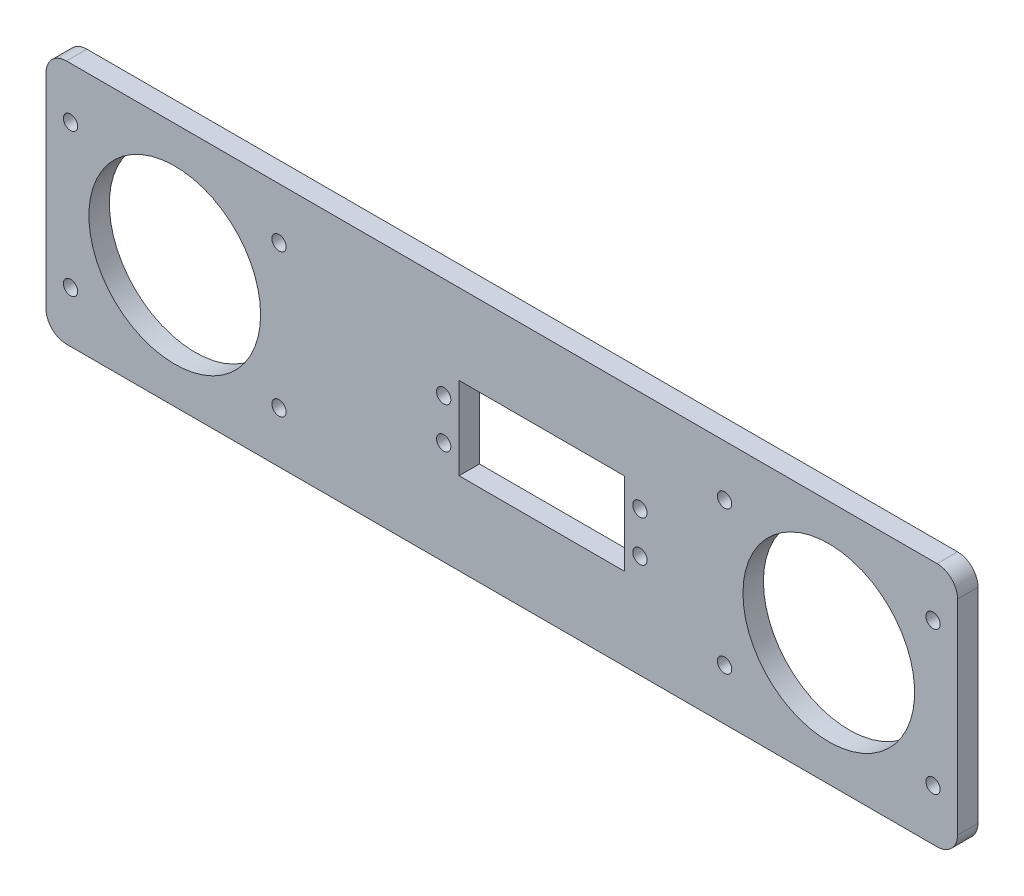
from build123d import *

# Parameters (mm, degrees)
SKETCH_1_R      = 21
SKETCH_1_R_2    = 1.75
SKETCH_1_W      = 40.5
SKETCH_1_H      = 20.2
EXTRUDE_1_DEPTH = 5


with BuildPart() as part:
    # 草图1 → 凸台-拉伸1 (new body)
    with BuildSketch(Plane.XY):
        with BuildLine():
            Line((106.5, -30), (-106.5, -30))
            ThreePointArc((-106.5, -30), (-110.035533906, -28.535533906), (-111.5, -25))
            Line((-111.5, -25), (-111.5, 25))
            ThreePointArc((-111.5, 25), (-110.035533906, 28.535533906), (-106.5, 30))
            Line((-106.5, 30), (106.5, 30))
            ThreePointArc((106.5, 30), (110.035533906, 28.535533906), (111.5, 25))
            Line((111.5, 25), (111.5, -25))
            ThreePointArc((111.5, -25), (110.035533906, -28.535533906), (106.5, -30))
        make_face()
        with Locations((-80, 0)):
            Circle(SKETCH_1_R, mode=Mode.SUBTRACT)
        with Locations((80, 0)):
            Circle(SKETCH_1_R, mode=Mode.SUBTRACT)
        with Locations((33.788860906, -4.762314657)):
            Circle(SKETCH_1_R_2, mode=Mode.SUBTRACT)
        with Locations((33.788860906, 5.237685343)):
            Circle(SKETCH_1_R_2, mode=Mode.SUBTRACT)
        with Locations((-14.211139094, -4.762314657)):
            Circle(SKETCH_1_R_2, mode=Mode.SUBTRACT)
        with Locations((-14.211139094, 5.237685343)):
            Circle(SKETCH_1_R_2, mode=Mode.SUBTRACT)
        with Locations((-54.5, -17.5)):
            Circle(SKETCH_1_R_2, mode=Mode.SUBTRACT)
        with Locations((-105.5, -17.5)):
            Circle(SKETCH_1_R_2, mode=Mode.SUBTRACT)
        with Locations((-105.5, 17.5)):
            Circle(SKETCH_1_R_2, mode=Mode.SUBTRACT)
        with Locations((-54.5, 17.5)):
            Circle(SKETCH_1_R_2, mode=Mode.SUBTRACT)
        with Locations((54.5, -17.5)):
            Circle(SKETCH_1_R_2, mode=Mode.SUBTRACT)
        with Locations((54.5, 17.5)):
            Circle(SKETCH_1_R_2, mode=Mode.SUBTRACT)
        with Locations((105.5, -17.5)):
            Circle(SKETCH_1_R_2, mode=Mode.SUBTRACT)
        with Locations((105.5, 17.5)):
            Circle(SKETCH_1_R_2, mode=Mode.SUBTRACT)
        with Locations((9.788860906, 0.237685343)):
            Rectangle(SKETCH_1_W, SKETCH_1_H, mode=Mode.SUBTRACT)
    extrude(amount=EXTRUDE_1_DEPTH)


solid = part.part
